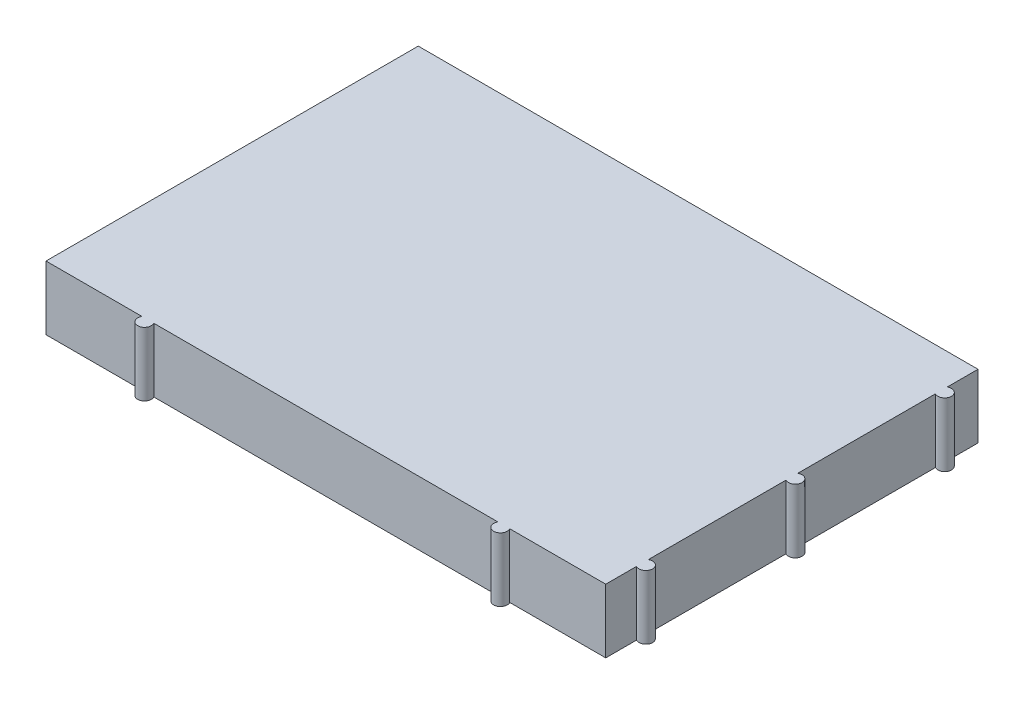
from build123d import *

# Parameters (mm, degrees)
BOSS_EXTRUDE1_DEPTH = 9.4


with BuildPart() as part:
    # Sketch1 → Boss-Extrude1 (new body)
    with BuildSketch(Plane(origin=(0, 0, 0), x_dir=(1, 0, 0), z_dir=(0, 1, 0))):
        with BuildLine():
            Line((-41.2, -27.4), (-27.066025404, -27.4))
            ThreePointArc((-27.066025404, -27.4), (-26.2, -28.9), (-25.333974596, -27.4))
            Line((-25.333974596, -27.4), (25.333974596, -27.4))
            ThreePointArc((25.333974596, -27.4), (26.2, -28.9), (27.066025404, -27.4))
            Line((27.066025404, -27.4), (41.2, -27.4))
            Line((41.2, -27.4), (41.2, -22.866025404))
            ThreePointArc((41.2, -22.866025404), (42.7, -22), (41.2, -21.133974596))
            Line((41.2, -21.133974596), (41.2, -0.866025404))
            ThreePointArc((41.2, -0.866025404), (42.7, 0), (41.2, 0.866025404))
            Line((41.2, 0.866025404), (41.2, 21.133974596))
            ThreePointArc((41.2, 21.133974596), (42.7, 22), (41.2, 22.866025404))
            Line((41.2, 22.866025404), (41.2, 27.4))
            Line((41.2, 27.4), (-41.2, 27.4))
            Line((-41.2, 27.4), (-41.2, -27.4))
        make_face()
    extrude(amount=BOSS_EXTRUDE1_DEPTH)


solid = part.part
